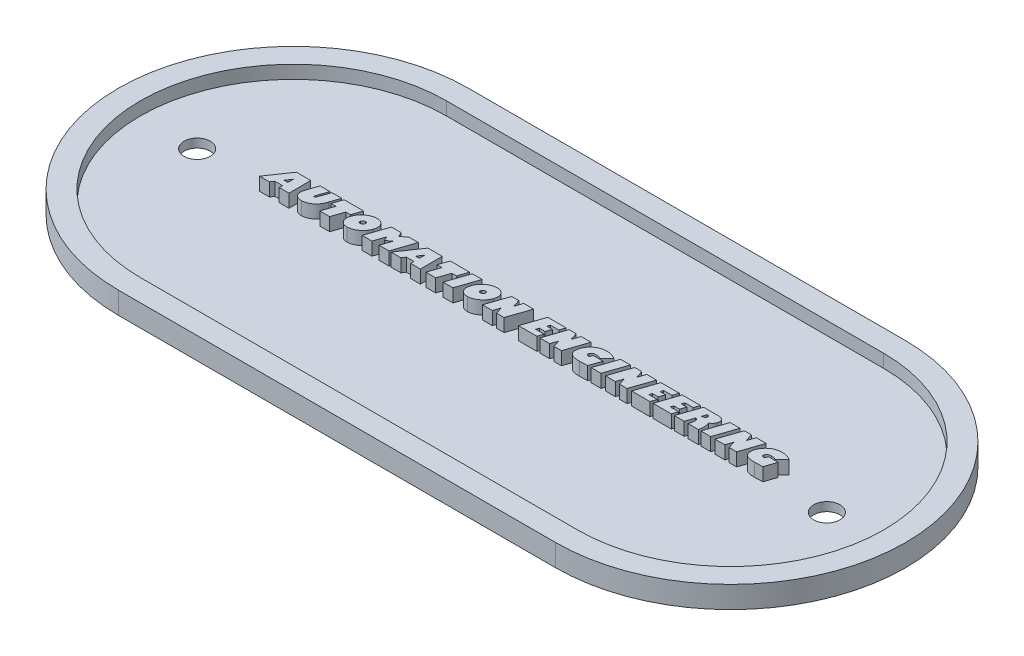
from build123d import *

# Parameters (mm, degrees)
BOSS_EXTRUDE1_DEPTH = 5
CUT_EXTRUDE1_DEPTH  = 3
BOSS_EXTRUDE2_DEPTH = 3
SKETCH4_R           = 3
CUT_EXTRUDE2_DEPTH  = 3


with BuildPart() as part:
    # Sketch1 → Boss-Extrude1 (new body)
    with BuildSketch(Plane(origin=(0, 0, 0), x_dir=(1, 0, 0), z_dir=(0, 1, 0))):
        with BuildLine():
            Line((0, 40), (100, 40))
            ThreePointArc((100, 40), (140, 0), (100, -40))
            Line((100, -40), (0, -40))
            ThreePointArc((0, -40), (-40, 0), (0, 40))
        make_face()
    extrude(amount=BOSS_EXTRUDE1_DEPTH)

    # Sketch2 → Cut-Extrude1 (cut)
    with BuildSketch(Plane(origin=(0, 5, 0), x_dir=(1, 0, 0), z_dir=(0, 1, 0))):
        with BuildLine():
            Line((100, 35), (0, 35))
            ThreePointArc((0, 35), (-35, 0), (0, -35))
            Line((0, -35), (100, -35))
            ThreePointArc((100, -35), (135, 0), (100, 35))
        make_face()
    extrude(amount=-CUT_EXTRUDE1_DEPTH, mode=Mode.SUBTRACT)

    # Sketch3 → Boss-Extrude2 (add)
    with BuildSketch(Plane(origin=(0, 2, 0), x_dir=(1, 0, 0), z_dir=(0, 1, 0))):
        Polygon((-4.188884775, -1.288840129), (-6.424236337, -1.288840129), (-3.008220712, 3.711159871), (0.265216788, 3.711159871), (0.288654288, -1.288840129), (-1.941814462, -1.288840129), (-1.92911915, -0.538840129), (-3.6908379, -0.538840129), align=None)
        Polygon((-2.821697275, 0.711159871), (-1.950603525, 0.711159871), (-1.957439462, 1.977761434), align=None, mode=Mode.SUBTRACT)
        with BuildLine():
            Line((7.350177725, 3.711159871), (6.5825996, 1.452370809))
            add(Edge.make_bspline(
                [(6.5825996, 1.452370809), (6.561528943, 1.391672481), (6.51993875, 1.271863444), (6.451088904, 1.096810885), (6.379022821, 0.927677441), (6.302731167, 0.765034597), (6.22419065, 0.608014453), (6.139413198, 0.458943169), (6.053201046, 0.314953178), (5.961679396, 0.178448604), (5.868605787, 0.046769398), (5.769267873, -0.076711984), (5.668200553, -0.195437621), (5.562169695, -0.306802321), (5.453113332, -0.412524789), (5.339333504, -0.511189098), (5.222532954, -0.603989697), (5.063174105, -0.717351463), (4.861401063, -0.845063964), (4.617489679, -0.980503928), (4.373406615, -1.094467347), (4.129495714, -1.187416274), (3.886308035, -1.261487565), (3.642971416, -1.313493016), (3.400138789, -1.344532245), (3.238284821, -1.34907902), (3.157794913, -1.351340129)],
                knots=[0, 0, 0, 0, 0.000192737, 0.000380433, 0.000564185, 0.000744182, 0.000919314, 0.001090714, 0.00125853, 0.001422665, 0.001583641, 0.001742103, 0.001897916, 0.00205127, 0.002203213, 0.002353416, 0.002502881, 0.002650575, 0.002939909, 0.003218776, 0.003487032, 0.003747293, 0.004001248, 0.004248904, 0.004492976, 0.004734426, 0.004734426, 0.004734426, 0.004734426], degree=3))
            add(Edge.make_bspline(
                [(3.157794913, -1.351340129), (3.100470526, -1.350126516), (2.987532139, -1.347735499), (2.821206213, -1.331477332), (2.66141658, -1.301644662), (2.507644689, -1.261677556), (2.359490277, -1.210998138), (2.217428305, -1.148184529), (2.081297703, -1.074036157), (1.9533166, -0.988182758), (1.834193504, -0.894750881), (1.728951938, -0.79141544), (1.637789293, -0.680655976), (1.559963329, -0.563097113), (1.496987468, -0.438225001), (1.449035389, -0.306027719), (1.41448879, -0.166633129), (1.395636398, -0.018879925), (1.389273303, 0.13788184), (1.394303174, 0.305630259), (1.412542864, 0.484918936), (1.442195983, 0.675862105), (1.483537547, 0.878159703), (1.536722396, 1.092072903), (1.600865349, 1.318023704), (1.651965434, 1.471120203), (1.678302725, 1.550027059)],
                knots=[0, 0, 0, 0, 0.000171975, 0.000338818, 0.000500672, 0.000659134, 0.000815094, 0.000969875, 0.001124582, 0.001279508, 0.001431717, 0.001578117, 0.001721036, 0.001861339, 0.00200022, 0.002139554, 0.002282376, 0.002430157, 0.002585581, 0.002752644, 0.002933189, 0.003125859, 0.003332127, 0.0035524, 0.003787013, 0.004036543, 0.004036543, 0.004036543, 0.004036543], degree=3))
            Line((1.678302725, 1.550027059), (2.412677725, 3.711159871))
            Line((2.412677725, 3.711159871), (4.662677725, 3.711159871))
            Line((4.662677725, 3.711159871), (3.878498038, 1.403542684))
            add(Edge.make_bspline(
                [(3.878498038, 1.403542684), (3.868716673, 1.373927013), (3.850153777, 1.317722928), (3.824105029, 1.238021314), (3.804728166, 1.166127365), (3.789319836, 1.103244779), (3.776840781, 1.049044283), (3.769844851, 1.003050708), (3.767147794, 0.965339942), (3.770791335, 0.927967408), (3.783336239, 0.891072187), (3.811518304, 0.858436501), (3.850952703, 0.838185602), (3.880834881, 0.836872517), (3.897052725, 0.836159871)],
                knots=[0, 0, 0, 0, 9.3572e-05, 0.000177579, 0.000251495, 0.000316866, 0.000371841, 0.000418246, 0.000456382, 0.000484853, 0.000530575, 0.000570721, 0.000611339, 0.000659548, 0.000659548, 0.000659548, 0.000659548], degree=3))
            add(Edge.make_bspline(
                [(3.897052725, 0.836159871), (3.92093615, 0.838096727), (3.969606578, 0.842043715), (4.036562184, 0.879977497), (4.097181554, 0.93703569), (4.138433596, 1.001842447), (4.171116763, 1.064180438), (4.198083722, 1.12025295), (4.226341622, 1.183780252), (4.255785125, 1.254838348), (4.286823132, 1.333259147), (4.318913157, 1.419703546), (4.353377858, 1.513241533), (4.375707893, 1.578623392), (4.3872871, 1.612527059)],
                knots=[0, 0, 0, 0, 7.1128e-05, 0.000144948, 0.000225097, 0.000319354, 0.000373525, 0.000436421, 0.000505928, 0.0005821, 0.000667151, 0.000758932, 0.000858718, 0.000966194, 0.000966194, 0.000966194, 0.000966194], degree=3))
            Line((4.3872871, 1.612527059), (5.100177725, 3.711159871))
            Line((5.100177725, 3.711159871), (7.350177725, 3.711159871))
        make_face()
        Polygon((7.148029288, 1.461159871), (7.912677725, 3.711159871), (12.350177725, 3.711159871), (11.585529288, 1.461159871), (10.523029288, 1.461159871), (9.588458975, -1.288840129), (7.338458975, -1.288840129), (8.273029288, 1.461159871), align=None)
        with BuildLine():
            add(Edge.make_bspline(
                [(13.627521475, -1.351340129), (13.583561474, -1.350796161), (13.497178768, -1.349727248), (13.370061346, -1.340762352), (13.24751814, -1.326131271), (13.12942109, -1.305935815), (13.015884943, -1.27897351), (12.906408034, -1.24882555), (12.802180551, -1.209593571), (12.701900593, -1.166603162), (12.606891004, -1.115895536), (12.515337937, -1.061392751), (12.428578039, -1.000261562), (12.347631328, -0.931600004), (12.268552167, -0.860356867), (12.197067883, -0.78018673), (12.127741694, -0.69634614), (12.065009853, -0.605837634), (12.007850315, -0.511302129), (11.955188469, -0.414358381), (11.911041513, -0.314131797), (11.872101974, -0.211665114), (11.841288813, -0.106445333), (11.816650147, 0.001162076), (11.799372931, 0.11148078), (11.787057102, 0.224220573), (11.783971005, 0.339726373), (11.785518224, 0.457403711), (11.794594015, 0.577691662), (11.810091757, 0.700604578), (11.833183498, 0.825887934), (11.860989714, 0.954214889), (11.897493007, 1.084636002), (11.925724318, 1.171866581), (11.940021475, 1.216042684)],
                knots=[0, 0, 0, 0, 0.000131868, 0.000259125, 0.000382072, 0.000502002, 0.000618311, 0.000732063, 0.000842363, 0.000952129, 0.001059151, 0.001165165, 0.001271651, 0.001377057, 0.001483479, 0.001590621, 0.00169891, 0.001809714, 0.001920587, 0.00203025, 0.002140411, 0.00224888, 0.002358881, 0.002469042, 0.00257982, 0.002693706, 0.002809007, 0.002926211, 0.003046649, 0.003170684, 0.003297686, 0.003428713, 0.003564469, 0.003703762, 0.003703762, 0.003703762, 0.003703762], degree=3))
            add(Edge.make_bspline(
                [(11.940021475, 1.216042684), (11.971985658, 1.304258434), (12.035715002, 1.480140664), (12.159168891, 1.732069312), (12.297987205, 1.975959106), (12.460684892, 2.207107088), (12.640632985, 2.430061961), (12.841440984, 2.641909651), (13.061779531, 2.84352157), (13.299578352, 3.031921176), (13.54701628, 3.205409179), (13.801004745, 3.356182338), (14.056617223, 3.485002992), (14.314294642, 3.590943377), (14.574981228, 3.672983786), (14.837852997, 3.729840741), (15.103024146, 3.767043349), (15.280719138, 3.771452009), (15.369708975, 3.773659871)],
                knots=[0, 0, 0, 0, 0.000281294, 0.000560837, 0.000840401, 0.001122413, 0.001407772, 0.001699295, 0.001997204, 0.002302995, 0.002608847, 0.00290311, 0.003188297, 0.003466848, 0.003738034, 0.004006974, 0.004272979, 0.004539838, 0.004539838, 0.004539838, 0.004539838], degree=3))
            add(Edge.make_bspline(
                [(15.369708975, 3.773659871), (15.413669609, 3.773113522), (15.500378341, 3.772035893), (15.628132506, 3.763031563), (15.751381162, 3.7486629), (15.869581057, 3.72781059), (15.983636095, 3.702916917), (16.092852199, 3.6706259), (16.197551722, 3.632056052), (16.298616716, 3.589726485), (16.394379939, 3.539645386), (16.485222335, 3.483455231), (16.572900297, 3.423355348), (16.654476411, 3.355587324), (16.732134157, 3.282913284), (16.805831307, 3.204807225), (16.873729993, 3.119765191), (16.936934697, 3.029860946), (16.995877113, 2.936959791), (17.046350284, 2.839471782), (17.091412339, 2.740196205), (17.129835694, 2.63814631), (17.160704685, 2.533234401), (17.186718259, 2.426181183), (17.20364598, 2.316023448), (17.215716524, 2.20394243), (17.220467709, 2.089126518), (17.218403626, 1.971755939), (17.209690353, 1.851758744), (17.193422991, 1.729356789), (17.172725142, 1.604259671), (17.142345679, 1.47722246), (17.107804747, 1.346973578), (17.079446051, 1.260186635), (17.065021475, 1.216042684)],
                knots=[0, 0, 0, 0, 0.000131868, 0.0002601, 0.000384015, 0.000503946, 0.000620038, 0.000734062, 0.000845278, 0.000954658, 0.001062545, 0.001169066, 0.001274991, 0.001381149, 0.001486857, 0.001593945, 0.001702993, 0.001812998, 0.001923553, 0.002032757, 0.002142028, 0.002250497, 0.002359562, 0.002469943, 0.002580722, 0.002693636, 0.002807998, 0.002925202, 0.003045641, 0.003168707, 0.00329554, 0.003425829, 0.003560386, 0.003699679, 0.003699679, 0.003699679, 0.003699679], degree=3))
            add(Edge.make_bspline(
                [(17.065021475, 1.216042684), (17.032630371, 1.127549038), (16.96809265, 0.951229694), (16.845235331, 0.697700717), (16.704721643, 0.453880407), (16.543698257, 0.220390278), (16.362309808, -0.002461392), (16.161736292, -0.215711568), (15.941212331, -0.418519028), (15.702944607, -0.60744186), (15.454827623, -0.781025454), (15.200913058, -0.93302984), (14.945202745, -1.062883668), (14.685886749, -1.167504316), (14.424969262, -1.250682962), (14.161002673, -1.30757896), (13.895180389, -1.34472064), (13.716836852, -1.349131265), (13.627521475, -1.351340129)],
                knots=[0, 0, 0, 0, 0.000282556, 0.000562979, 0.000843878, 0.001126136, 0.001412869, 0.001705102, 0.002003672, 0.002310835, 0.002616687, 0.002911451, 0.003197948, 0.003476131, 0.003749473, 0.004018413, 0.004285386, 0.004553221, 0.004553221, 0.004553221, 0.004553221], degree=3))
        make_face()
        with BuildLine():
            add(Edge.make_bspline(
                [(14.71150585, 1.836159871), (14.676189649, 1.834465178), (14.605543719, 1.831075142), (14.501346221, 1.803457787), (14.400786652, 1.75763273), (14.305681986, 1.695347215), (14.217974186, 1.621389385), (14.144331495, 1.53545469), (14.083828594, 1.440734529), (14.057043783, 1.371215826), (14.0435371, 1.336159871)],
                knots=[0, 0, 0, 0, 0.000105834, 0.000211709, 0.00032098, 0.000436102, 0.00055177, 0.000663943, 0.000774498, 0.000886955, 0.000886955, 0.000886955, 0.000886955], degree=3))
            add(Edge.make_bspline(
                [(14.0435371, 1.336159871), (14.033416355, 1.301951851), (14.01439594, 1.237663029), (14.007373001, 1.1412063), (14.023193221, 1.053519495), (14.059257316, 0.976062661), (14.115577298, 0.9130412), (14.187828074, 0.867172941), (14.27545321, 0.840264738), (14.338259639, 0.837585027), (14.3716621, 0.836159871)],
                knots=[0, 0, 0, 0, 0.000106821, 0.000200754, 0.00028714, 0.000371447, 0.000453763, 0.0005372, 0.000625226, 0.000725223, 0.000725223, 0.000725223, 0.000725223], degree=3))
            add(Edge.make_bspline(
                [(14.3716621, 0.836159871), (14.407622887, 0.837845869), (14.479224196, 0.841202848), (14.584528146, 0.868592362), (14.684957772, 0.914912651), (14.781050636, 0.975771676), (14.867835643, 1.050998061), (14.941676502, 1.137090313), (15.003400896, 1.231293615), (15.030103323, 1.301060641), (15.0435371, 1.336159871)],
                knots=[0, 0, 0, 0, 0.000107781, 0.000214602, 0.000323872, 0.000438467, 0.000554773, 0.000666946, 0.000778021, 0.000890478, 0.000890478, 0.000890478, 0.000890478], degree=3))
            add(Edge.make_bspline(
                [(15.0435371, 1.336159871), (15.053799453, 1.370363934), (15.073080634, 1.434627434), (15.07834329, 1.531113454), (15.06325572, 1.618627187), (15.026207804, 1.695509823), (14.970922983, 1.759283517), (14.897966979, 1.805339297), (14.809326311, 1.832109566), (14.745558356, 1.83474991), (14.71150585, 1.836159871)],
                knots=[0, 0, 0, 0, 0.000106821, 0.000200698, 0.000287084, 0.00037051, 0.000453558, 0.000536995, 0.000625954, 0.000727896, 0.000727896, 0.000727896, 0.000727896], degree=3))
        make_face(mode=Mode.SUBTRACT)
        Polygon((17.025958975, -1.288840129), (18.725177725, 3.711159871), (20.908771475, 3.711159871), (21.431232413, 2.663308309), (22.669513663, 3.711159871), (24.850177725, 3.711159871), (23.150958975, -1.288840129), (20.900958975, -1.288840129), (21.7466621, 1.198464559), (20.603107413, 0.225808309), (20.1216621, 1.198464559), (19.275958975, -1.288840129), align=None)
        Polygon((25.873615225, -1.288840129), (23.638263663, -1.288840129), (27.054279288, 3.711159871), (30.327716788, 3.711159871), (30.351154288, -1.288840129), (28.120685538, -1.288840129), (28.13338085, -0.538840129), (26.3716621, -0.538840129), align=None)
        Polygon((27.240802725, 0.711159871), (28.111896475, 0.711159871), (28.105060538, 1.977761434), align=None, mode=Mode.SUBTRACT)
        Polygon((31.398029288, 1.461159871), (32.162677725, 3.711159871), (36.600177725, 3.711159871), (35.835529288, 1.461159871), (34.773029288, 1.461159871), (33.838458975, -1.288840129), (31.588458975, -1.288840129), (32.523029288, 1.461159871), align=None)
        Polygon((35.525958975, -1.288840129), (37.225177725, 3.711159871), (39.475177725, 3.711159871), (37.775958975, -1.288840129), align=None)
        with BuildLine():
            add(Edge.make_bspline(
                [(41.127521475, -1.351340129), (41.083561474, -1.350796161), (40.997178768, -1.349727248), (40.870061346, -1.340762352), (40.74751814, -1.326131271), (40.62942109, -1.305935815), (40.515884943, -1.27897351), (40.406408034, -1.24882555), (40.302180551, -1.209593571), (40.201900593, -1.166603162), (40.106891004, -1.115895536), (40.015337937, -1.061392751), (39.928578039, -1.000261562), (39.847631328, -0.931600004), (39.768552167, -0.860356867), (39.697067883, -0.78018673), (39.627741694, -0.69634614), (39.565009853, -0.605837634), (39.507850315, -0.511302129), (39.455188469, -0.414358381), (39.411041513, -0.314131797), (39.372101974, -0.211665114), (39.341288813, -0.106445333), (39.316650147, 0.001162076), (39.299372931, 0.11148078), (39.287057102, 0.224220573), (39.283971005, 0.339726373), (39.285518224, 0.457403711), (39.294594015, 0.577691662), (39.310091757, 0.700604578), (39.333183498, 0.825887934), (39.360989714, 0.954214889), (39.397493007, 1.084636002), (39.425724318, 1.171866581), (39.440021475, 1.216042684)],
                knots=[0, 0, 0, 0, 0.000131868, 0.000259125, 0.000382072, 0.000502002, 0.000618311, 0.000732063, 0.000842363, 0.000952129, 0.001059151, 0.001165165, 0.001271651, 0.001377057, 0.001483479, 0.001590621, 0.00169891, 0.001809714, 0.001920587, 0.00203025, 0.002140411, 0.00224888, 0.002358881, 0.002469042, 0.00257982, 0.002693706, 0.002809007, 0.002926211, 0.003046649, 0.003170684, 0.003297686, 0.003428713, 0.003564469, 0.003703762, 0.003703762, 0.003703762, 0.003703762], degree=3))
            add(Edge.make_bspline(
                [(39.440021475, 1.216042684), (39.471985658, 1.304258434), (39.535715002, 1.480140664), (39.659168891, 1.732069312), (39.797987205, 1.975959106), (39.960684892, 2.207107088), (40.140632985, 2.430061961), (40.341440984, 2.641909651), (40.561779531, 2.84352157), (40.799578352, 3.031921176), (41.04701628, 3.205409179), (41.301004745, 3.356182338), (41.556617223, 3.485002992), (41.814294642, 3.590943377), (42.074981228, 3.672983786), (42.337852997, 3.729840741), (42.603024146, 3.767043349), (42.780719138, 3.771452009), (42.869708975, 3.773659871)],
                knots=[0, 0, 0, 0, 0.000281294, 0.000560837, 0.000840401, 0.001122413, 0.001407772, 0.001699295, 0.001997204, 0.002302995, 0.002608847, 0.00290311, 0.003188297, 0.003466848, 0.003738034, 0.004006974, 0.004272979, 0.004539838, 0.004539838, 0.004539838, 0.004539838], degree=3))
            add(Edge.make_bspline(
                [(42.869708975, 3.773659871), (42.913669609, 3.773113522), (43.000378341, 3.772035893), (43.128132506, 3.763031563), (43.251381162, 3.7486629), (43.369581057, 3.72781059), (43.483636095, 3.702916917), (43.592852199, 3.6706259), (43.697551722, 3.632056052), (43.798616716, 3.589726485), (43.894379939, 3.539645386), (43.985222335, 3.483455231), (44.072900297, 3.423355348), (44.154476411, 3.355587324), (44.232134157, 3.282913284), (44.305831307, 3.204807225), (44.373729993, 3.119765191), (44.436934697, 3.029860946), (44.495877113, 2.936959791), (44.546350284, 2.839471782), (44.591412339, 2.740196205), (44.629835694, 2.63814631), (44.660704685, 2.533234401), (44.686718259, 2.426181183), (44.70364598, 2.316023448), (44.715716524, 2.20394243), (44.720467709, 2.089126518), (44.718403626, 1.971755939), (44.709690353, 1.851758744), (44.693422991, 1.729356789), (44.672725142, 1.604259671), (44.642345679, 1.47722246), (44.607804747, 1.346973578), (44.579446051, 1.260186635), (44.565021475, 1.216042684)],
                knots=[0, 0, 0, 0, 0.000131868, 0.0002601, 0.000384015, 0.000503946, 0.000620038, 0.000734062, 0.000845278, 0.000954658, 0.001062545, 0.001169066, 0.001274991, 0.001381149, 0.001486857, 0.001593945, 0.001702993, 0.001812998, 0.001923553, 0.002032757, 0.002142028, 0.002250497, 0.002359562, 0.002469943, 0.002580722, 0.002693636, 0.002807998, 0.002925202, 0.003045641, 0.003168707, 0.00329554, 0.003425829, 0.003560386, 0.003699679, 0.003699679, 0.003699679, 0.003699679], degree=3))
            add(Edge.make_bspline(
                [(44.565021475, 1.216042684), (44.532630371, 1.127549038), (44.46809265, 0.951229694), (44.345235331, 0.697700717), (44.204721643, 0.453880407), (44.043698257, 0.220390278), (43.862309808, -0.002461392), (43.661736292, -0.215711568), (43.441212331, -0.418519028), (43.202944607, -0.60744186), (42.954827623, -0.781025454), (42.700913058, -0.93302984), (42.445202745, -1.062883668), (42.185886749, -1.167504316), (41.924969262, -1.250682962), (41.661002673, -1.30757896), (41.395180389, -1.34472064), (41.216836852, -1.349131265), (41.127521475, -1.351340129)],
                knots=[0, 0, 0, 0, 0.000282556, 0.000562979, 0.000843878, 0.001126136, 0.001412869, 0.001705102, 0.002003672, 0.002310835, 0.002616687, 0.002911451, 0.003197948, 0.003476131, 0.003749473, 0.004018413, 0.004285386, 0.004553221, 0.004553221, 0.004553221, 0.004553221], degree=3))
        make_face()
        with BuildLine():
            add(Edge.make_bspline(
                [(42.21150585, 1.836159871), (42.176189649, 1.834465178), (42.105543719, 1.831075142), (42.001346221, 1.803457787), (41.900786652, 1.75763273), (41.805681986, 1.695347215), (41.717974186, 1.621389385), (41.644331495, 1.53545469), (41.583828594, 1.440734529), (41.557043783, 1.371215826), (41.5435371, 1.336159871)],
                knots=[0, 0, 0, 0, 0.000105834, 0.000211709, 0.00032098, 0.000436102, 0.00055177, 0.000663943, 0.000774498, 0.000886955, 0.000886955, 0.000886955, 0.000886955], degree=3))
            add(Edge.make_bspline(
                [(41.5435371, 1.336159871), (41.533416355, 1.301951851), (41.51439594, 1.237663029), (41.507373001, 1.1412063), (41.523193221, 1.053519495), (41.559257316, 0.976062661), (41.615577298, 0.9130412), (41.687828074, 0.867172941), (41.77545321, 0.840264738), (41.838259639, 0.837585027), (41.8716621, 0.836159871)],
                knots=[0, 0, 0, 0, 0.000106821, 0.000200754, 0.00028714, 0.000371447, 0.000453763, 0.0005372, 0.000625226, 0.000725223, 0.000725223, 0.000725223, 0.000725223], degree=3))
            add(Edge.make_bspline(
                [(41.8716621, 0.836159871), (41.907622887, 0.837845869), (41.979224196, 0.841202848), (42.084528146, 0.868592362), (42.184957772, 0.914912651), (42.281050636, 0.975771676), (42.367835643, 1.050998061), (42.441676502, 1.137090313), (42.503400896, 1.231293615), (42.530103323, 1.301060641), (42.5435371, 1.336159871)],
                knots=[0, 0, 0, 0, 0.000107781, 0.000214602, 0.000323872, 0.000438467, 0.000554773, 0.000666946, 0.000778021, 0.000890478, 0.000890478, 0.000890478, 0.000890478], degree=3))
            add(Edge.make_bspline(
                [(42.5435371, 1.336159871), (42.553799453, 1.370363934), (42.573080634, 1.434627434), (42.57834329, 1.531113454), (42.56325572, 1.618627187), (42.526207804, 1.695509823), (42.470922983, 1.759283517), (42.397966979, 1.805339297), (42.309326311, 1.832109566), (42.245558356, 1.83474991), (42.21150585, 1.836159871)],
                knots=[0, 0, 0, 0, 0.000106821, 0.000200698, 0.000287084, 0.00037051, 0.000453558, 0.000536995, 0.000625954, 0.000727896, 0.000727896, 0.000727896, 0.000727896], degree=3))
        make_face(mode=Mode.SUBTRACT)
        Polygon((49.5122871, -1.327902629), (47.808185538, -1.327902629), (47.3013496, 0.257058309), (46.775958975, -1.288840129), (44.525958975, -1.288840129), (46.225177725, 3.711159871), (47.835529288, 3.711159871), (48.397052725, 2.010964559), (48.975177725, 3.711159871), (51.225177725, 3.711159871), align=None)
        Polygon((57.388263663, -0.038840129), (56.963458975, -1.288840129), (52.775958975, -1.288840129), (54.475177725, 3.711159871), (58.662677725, 3.711159871), (58.237873038, 2.461159871), (56.331623038, 2.461159871), (56.119708975, 1.836159871), (57.400958975, 1.836159871), (56.976154288, 0.586159871), (55.663654288, 0.586159871), (55.450763663, -0.038840129), align=None)
        Polygon((62.6372871, -1.327902629), (60.933185538, -1.327902629), (60.4263496, 0.257058309), (59.900958975, -1.288840129), (57.650958975, -1.288840129), (59.350177725, 3.711159871), (60.960529288, 3.711159871), (61.522052725, 2.010964559), (62.100177725, 3.711159871), (64.350177725, 3.711159871), align=None)
        with BuildLine():
            Line((70.19588085, 3.081277059), (68.607013663, 1.523659871))
            add(Edge.make_bspline(
                [(68.607013663, 1.523659871), (68.558768212, 1.548600632), (68.463771603, 1.597709671), (68.318401461, 1.661477226), (68.172938437, 1.715215122), (68.027184635, 1.759331591), (67.88139754, 1.793687303), (67.735588525, 1.818055305), (67.589762448, 1.833326946), (67.492466667, 1.835216974), (67.443927725, 1.836159871)],
                knots=[0, 0, 0, 0, 0.000162902, 0.000320758, 0.000475862, 0.000627861, 0.00077733, 0.000924871, 0.001071115, 0.001216704, 0.001216704, 0.001216704, 0.001216704], degree=3))
            add(Edge.make_bspline(
                [(67.443927725, 1.836159871), (67.381271739, 1.834278731), (67.258614756, 1.830596163), (67.080899729, 1.796450239), (66.914463757, 1.741596048), (66.786142868, 1.67735265), (66.692386589, 1.615727418), (66.627269712, 1.567381106), (66.569777954, 1.513719148), (66.516438936, 1.458568587), (66.470205671, 1.398653695), (66.43137348, 1.33430283), (66.39651637, 1.26751725), (66.379291492, 1.220168156), (66.370685538, 1.196511434)],
                knots=[0, 0, 0, 0, 0.000187807, 0.000367657, 0.000540594, 0.00071223, 0.000796197, 0.000877058, 0.000955164, 0.001031842, 0.001107043, 0.001181576, 0.001257132, 0.001332574, 0.001332574, 0.001332574, 0.001332574], degree=3))
            add(Edge.make_bspline(
                [(66.370685538, 1.196511434), (66.363723965, 1.174499612), (66.350463534, 1.132571404), (66.33839501, 1.070024358), (66.334303413, 1.011973886), (66.337666311, 0.957462828), (66.350765483, 0.907845143), (66.370046005, 0.861827991), (66.398654812, 0.821047612), (66.433747205, 0.783632265), (66.47751682, 0.751234031), (66.529108824, 0.724043147), (66.588110698, 0.700773485), (66.654719203, 0.68116814), (66.72935199, 0.667042899), (66.811526416, 0.656495496), (66.901487045, 0.649388529), (66.964095504, 0.6489092), (66.9966621, 0.648659871)],
                knots=[0, 0, 0, 0, 6.9219e-05, 0.000131848, 0.000190572, 0.000243451, 0.000294848, 0.000343833, 0.000392318, 0.000443436, 0.000497147, 0.000554822, 0.000617929, 0.000687148, 0.000762799, 0.00084553, 0.000935634, 0.00103331, 0.00103331, 0.00103331, 0.00103331], degree=3))
            Line((66.9966621, 0.648659871), (67.2310371, 1.336159871))
            Line((67.2310371, 1.336159871), (69.4810371, 1.336159871))
            Line((69.4810371, 1.336159871), (68.592365225, -1.278097941))
            add(Edge.make_bspline(
                [(68.592365225, -1.278097941), (68.482020774, -1.284098324), (68.270795419, -1.295584475), (67.968023567, -1.309821627), (67.693644615, -1.323027586), (67.447197522, -1.332518182), (67.228776223, -1.340505604), (67.038343139, -1.34623131), (66.876241531, -1.350829812), (66.777589037, -1.351181251), (66.732990225, -1.351340129)],
                knots=[0, 0, 0, 0, 0.000331521, 0.00063461, 0.000909317, 0.001155605, 0.001374494, 0.001565014, 0.00172717, 0.001860963, 0.001860963, 0.001860963, 0.001860963], degree=3))
            add(Edge.make_bspline(
                [(66.732990225, -1.351340129), (66.657787161, -1.350782457), (66.510908269, -1.34969327), (66.295925087, -1.341077441), (66.091705937, -1.325525392), (65.898339042, -1.303670473), (65.715205888, -1.278573704), (65.543765491, -1.243683643), (65.38293883, -1.205042851), (65.233012923, -1.160481271), (65.09417482, -1.108597031), (64.965770118, -1.051191726), (64.848247512, -0.987575792), (64.740875403, -0.918790141), (64.646241451, -0.841530909), (64.560031572, -0.76100611), (64.486525882, -0.672354609), (64.404108932, -0.547226924), (64.320147166, -0.382005116), (64.243630163, -0.174740259), (64.190927718, 0.040446326), (64.166429439, 0.263851809), (64.165316922, 0.494684598), (64.190887013, 0.733418144), (64.240341355, 0.9804865), (64.292271774, 1.144532811), (64.318927725, 1.228737996)],
                knots=[0, 0, 0, 0, 0.000225605, 0.000440628, 0.000645327, 0.000839876, 0.001024387, 0.001199628, 0.001364479, 0.0015205, 0.001668516, 0.001808822, 0.001942097, 0.002069133, 0.002190686, 0.002308109, 0.002422517, 0.002535191, 0.002757066, 0.002976749, 0.00319679, 0.003419919, 0.003649414, 0.003887971, 0.004139054, 0.004403861, 0.004403861, 0.004403861, 0.004403861], degree=3))
            add(Edge.make_bspline(
                [(64.318927725, 1.228737996), (64.339727531, 1.287594194), (64.381326012, 1.405303386), (64.456121758, 1.577319214), (64.540586254, 1.745464268), (64.632851289, 1.910426028), (64.735220128, 2.071012174), (64.845673912, 2.228647021), (64.965461038, 2.382899478), (65.09533872, 2.531779461), (65.232519512, 2.674867423), (65.376340734, 2.811035663), (65.526653973, 2.939199977), (65.684072338, 3.0581453), (65.847456904, 3.169074739), (66.017774153, 3.270303287), (66.193950658, 3.364405095), (66.375965986, 3.45024878), (66.563778938, 3.526420376), (66.755712562, 3.592845723), (66.951768108, 3.648397612), (67.151118691, 3.694678624), (67.354655351, 3.729545225), (67.561601365, 3.754708138), (67.772435946, 3.771200526), (67.914274317, 3.772834511), (67.985919913, 3.773659871)],
                knots=[0, 0, 0, 0, 0.000187225, 0.00037444, 0.000562235, 0.000751562, 0.000941206, 0.001133294, 0.001328833, 0.001526808, 0.001725725, 0.001923295, 0.002120737, 0.002318005, 0.002514918, 0.002712878, 0.002912097, 0.003113925, 0.003316306, 0.003519828, 0.003722917, 0.003927355, 0.0041335, 0.004342083, 0.004552624, 0.004767523, 0.004767523, 0.004767523, 0.004767523], degree=3))
            add(Edge.make_bspline(
                [(67.985919913, 3.773659871), (68.086908724, 3.77119939), (68.288768755, 3.766281293), (68.590363337, 3.732888979), (68.888993105, 3.674145287), (69.182605219, 3.596116328), (69.465408928, 3.498066161), (69.729359014, 3.378397696), (69.974432502, 3.242451883), (70.122663697, 3.134566062), (70.19588085, 3.081277059)],
                knots=[0, 0, 0, 0, 0.000302961, 0.000605569, 0.000908943, 0.001215232, 0.001516363, 0.001805703, 0.002083815, 0.002355266, 0.002355266, 0.002355266, 0.002355266], degree=3))
        make_face()
        Polygon((69.400958975, -1.288840129), (71.100177725, 3.711159871), (73.350177725, 3.711159871), (71.650958975, -1.288840129), align=None)
        Polygon((77.6372871, -1.327902629), (75.933185538, -1.327902629), (75.4263496, 0.257058309), (74.900958975, -1.288840129), (72.650958975, -1.288840129), (74.350177725, 3.711159871), (75.960529288, 3.711159871), (76.522052725, 2.010964559), (77.100177725, 3.711159871), (79.350177725, 3.711159871), align=None)
        Polygon((83.263263663, -0.038840129), (82.838458975, -1.288840129), (78.650958975, -1.288840129), (80.350177725, 3.711159871), (84.537677725, 3.711159871), (84.112873038, 2.461159871), (82.206623038, 2.461159871), (81.994708975, 1.836159871), (83.275958975, 1.836159871), (82.851154288, 0.586159871), (81.538654288, 0.586159871), (81.325763663, -0.038840129), align=None)
        Polygon((88.138263663, -0.038840129), (87.713458975, -1.288840129), (83.525958975, -1.288840129), (85.225177725, 3.711159871), (89.412677725, 3.711159871), (88.987873038, 2.461159871), (87.081623038, 2.461159871), (86.869708975, 1.836159871), (88.150958975, 1.836159871), (87.726154288, 0.586159871), (86.413654288, 0.586159871), (86.200763663, -0.038840129), align=None)
        with BuildLine():
            Line((90.100177725, 3.711159871), (93.392169913, 3.711159871))
            add(Edge.make_bspline(
                [(93.392169913, 3.711159871), (93.460902178, 3.709866687), (93.593129039, 3.707378865), (93.783912321, 3.687924929), (93.958800216, 3.655212174), (94.117996567, 3.609687573), (94.261285993, 3.551193156), (94.388652099, 3.478657297), (94.500121881, 3.392099665), (94.595010917, 3.29303643), (94.673703344, 3.184751849), (94.733415203, 3.068102759), (94.777341006, 2.945796677), (94.802610024, 2.816455264), (94.810178569, 2.680476394), (94.799658409, 2.537940561), (94.772441879, 2.388818977), (94.741258255, 2.289644928), (94.725177725, 2.238503621)],
                knots=[0, 0, 0, 0, 0.000206168, 0.000396625, 0.000574555, 0.000739282, 0.000892528, 0.00103776, 0.001177627, 0.00131438, 0.001447998, 0.00157772, 0.001706211, 0.001836636, 0.001971628, 0.002113566, 0.002264501, 0.002425204, 0.002425204, 0.002425204, 0.002425204], degree=3))
            add(Edge.make_bspline(
                [(94.725177725, 2.238503621), (94.704229436, 2.181678839), (94.66251584, 2.068525636), (94.579145767, 1.908623458), (94.483458751, 1.757129375), (94.372134595, 1.615516495), (94.24578672, 1.483905859), (94.10531156, 1.360894611), (93.949551574, 1.248494103), (93.837700722, 1.182306218), (93.780841788, 1.148659871)],
                knots=[0, 0, 0, 0, 0.000181528, 0.00036147, 0.000539729, 0.000718483, 0.000900831, 0.001086311, 0.001277941, 0.001476078, 0.001476078, 0.001476078, 0.001476078], degree=3))
            add(Edge.make_bspline(
                [(93.780841788, 1.148659871), (93.799820347, 1.10881136), (93.837958354, 1.02873453), (93.887702697, 0.904557708), (93.930608923, 0.775972475), (93.967973699, 0.643114717), (93.997950315, 0.505786615), (94.021381686, 0.363966013), (94.03893862, 0.218337821), (94.049767006, 0.067774555), (94.053196367, -0.086676597), (94.05146193, -0.245977798), (94.042665395, -0.409212175), (94.026497728, -0.576872402), (94.005356905, -0.748928536), (93.976522528, -0.925311973), (93.942900768, -1.106236739), (93.915069023, -1.227408741), (93.900958975, -1.288840129)],
                knots=[0, 0, 0, 0, 0.000132388, 0.000266038, 0.000400991, 0.000538891, 0.000679875, 0.000822439, 0.000969975, 0.001119774, 0.001275097, 0.001433312, 0.00159761, 0.001765331, 0.001938544, 0.002117556, 0.002301425, 0.002490498, 0.002490498, 0.002490498, 0.002490498], degree=3))
            Line((93.900958975, -1.288840129), (91.588458975, -1.288840129))
            add(Edge.make_bspline(
                [(91.588458975, -1.288840129), (91.610379742, -1.209204), (91.652647036, -1.055650809), (91.706673291, -0.831958035), (91.748857047, -0.624238843), (91.784747074, -0.43347981), (91.806730676, -0.258315745), (91.820464739, -0.099312714), (91.822463754, 0.043602757), (91.815868669, 0.170890727), (91.796865402, 0.282875177), (91.766133704, 0.381060304), (91.721088948, 0.464075761), (91.663254616, 0.532816084), (91.592172477, 0.585342113), (91.508872283, 0.623418369), (91.412691174, 0.644118242), (91.344738345, 0.647099207), (91.3091621, 0.648659871)],
                knots=[0, 0, 0, 0, 0.000247787, 0.00047778, 0.000690179, 0.000883652, 0.001059894, 0.001219579, 0.00136217, 0.001488389, 0.001601417, 0.001702093, 0.001795619, 0.0018829, 0.001969424, 0.00205857, 0.002155702, 0.002262434, 0.002262434, 0.002262434, 0.002262434], degree=3))
            Line((91.3091621, 0.648659871), (90.650958975, -1.288840129))
            Line((90.650958975, -1.288840129), (88.400958975, -1.288840129))
            Line((88.400958975, -1.288840129), (90.100177725, 3.711159871))
        make_face()
        with BuildLine():
            Line((91.9888496, 2.648659871), (91.670490225, 1.711159871))
            Line((91.670490225, 1.711159871), (91.729083975, 1.711159871))
            add(Edge.make_bspline(
                [(91.729083975, 1.711159871), (91.774094202, 1.712304372), (91.86076889, 1.714508299), (91.984447397, 1.735899088), (92.095431102, 1.772045038), (92.193463042, 1.822277228), (92.279748584, 1.886186238), (92.350028375, 1.967523634), (92.410273935, 2.060760458), (92.437037055, 2.131125068), (92.450763663, 2.167214559)],
                knots=[0, 0, 0, 0, 0.000134939, 0.000259847, 0.000375036, 0.00048379, 0.000589064, 0.000694899, 0.000804626, 0.000920162, 0.000920162, 0.000920162, 0.000920162], degree=3))
            add(Edge.make_bspline(
                [(92.450763663, 2.167214559), (92.460002462, 2.197893973), (92.477645325, 2.256480882), (92.485737609, 2.345015588), (92.477246781, 2.427837235), (92.455990141, 2.49175261), (92.430562274, 2.537962541), (92.404196003, 2.568079966), (92.371696046, 2.593428601), (92.332762851, 2.61431582), (92.287377519, 2.62928195), (92.236127456, 2.641256219), (92.178473131, 2.647843469), (92.137953536, 2.64837967), (92.116779288, 2.648659871)],
                knots=[0, 0, 0, 0, 9.5932e-05, 0.000183197, 0.000264726, 0.000344093, 0.000383459, 0.000422228, 0.000463255, 0.000506511, 0.000554073, 0.000606189, 0.00066421, 0.000727717, 0.000727717, 0.000727717, 0.000727717], degree=3))
            Line((92.116779288, 2.648659871), (91.9888496, 2.648659871))
        make_face(mode=Mode.SUBTRACT)
        Polygon((94.463458975, -1.288840129), (96.162677725, 3.711159871), (98.412677725, 3.711159871), (96.713458975, -1.288840129), align=None)
        Polygon((102.6997871, -1.327902629), (100.995685538, -1.327902629), (100.4888496, 0.257058309), (99.963458975, -1.288840129), (97.713458975, -1.288840129), (99.412677725, 3.711159871), (101.023029288, 3.711159871), (101.584552725, 2.010964559), (102.162677725, 3.711159871), (104.412677725, 3.711159871), align=None)
        with BuildLine():
            Line((110.25838085, 3.081277059), (108.669513663, 1.523659871))
            add(Edge.make_bspline(
                [(108.669513663, 1.523659871), (108.621268212, 1.548600632), (108.526271603, 1.597709671), (108.380901461, 1.661477226), (108.235438437, 1.715215122), (108.089684635, 1.759331591), (107.94389754, 1.793687303), (107.798088525, 1.818055305), (107.652262448, 1.833326946), (107.554966667, 1.835216974), (107.506427725, 1.836159871)],
                knots=[0, 0, 0, 0, 0.000162902, 0.000320758, 0.000475862, 0.000627861, 0.00077733, 0.000924871, 0.001071115, 0.001216704, 0.001216704, 0.001216704, 0.001216704], degree=3))
            add(Edge.make_bspline(
                [(107.506427725, 1.836159871), (107.443771739, 1.834278731), (107.321114756, 1.830596163), (107.143399729, 1.796450239), (106.976963757, 1.741596048), (106.848642868, 1.67735265), (106.754886589, 1.615727418), (106.689769712, 1.567381106), (106.632277954, 1.513719148), (106.578938936, 1.458568587), (106.532705671, 1.398653695), (106.49387348, 1.33430283), (106.45901637, 1.26751725), (106.441791492, 1.220168156), (106.433185538, 1.196511434)],
                knots=[0, 0, 0, 0, 0.000187807, 0.000367657, 0.000540594, 0.00071223, 0.000796197, 0.000877058, 0.000955164, 0.001031842, 0.001107043, 0.001181576, 0.001257132, 0.001332574, 0.001332574, 0.001332574, 0.001332574], degree=3))
            add(Edge.make_bspline(
                [(106.433185538, 1.196511434), (106.426223965, 1.174499612), (106.412963534, 1.132571404), (106.40089501, 1.070024358), (106.396803413, 1.011973886), (106.400166311, 0.957462828), (106.413265483, 0.907845143), (106.432546005, 0.861827991), (106.461154812, 0.821047612), (106.496247205, 0.783632265), (106.54001682, 0.751234031), (106.591608824, 0.724043147), (106.650610698, 0.700773485), (106.717219203, 0.68116814), (106.79185199, 0.667042899), (106.874026416, 0.656495496), (106.963987045, 0.649388529), (107.026595504, 0.6489092), (107.0591621, 0.648659871)],
                knots=[0, 0, 0, 0, 6.9219e-05, 0.000131848, 0.000190572, 0.000243451, 0.000294848, 0.000343833, 0.000392318, 0.000443436, 0.000497147, 0.000554822, 0.000617929, 0.000687148, 0.000762799, 0.00084553, 0.000935634, 0.00103331, 0.00103331, 0.00103331, 0.00103331], degree=3))
            Line((107.0591621, 0.648659871), (107.2935371, 1.336159871))
            Line((107.2935371, 1.336159871), (109.5435371, 1.336159871))
            Line((109.5435371, 1.336159871), (108.654865225, -1.278097941))
            add(Edge.make_bspline(
                [(108.654865225, -1.278097941), (108.544520774, -1.284098324), (108.333295419, -1.295584475), (108.030523567, -1.309821627), (107.756144615, -1.323027586), (107.509697522, -1.332518182), (107.291276223, -1.340505604), (107.100843139, -1.34623131), (106.938741531, -1.350829812), (106.840089037, -1.351181251), (106.795490225, -1.351340129)],
                knots=[0, 0, 0, 0, 0.000331521, 0.00063461, 0.000909317, 0.001155605, 0.001374494, 0.001565014, 0.00172717, 0.001860963, 0.001860963, 0.001860963, 0.001860963], degree=3))
            add(Edge.make_bspline(
                [(106.795490225, -1.351340129), (106.720287161, -1.350782457), (106.573408269, -1.34969327), (106.358425087, -1.341077441), (106.154205937, -1.325525392), (105.960839042, -1.303670473), (105.777705888, -1.278573704), (105.606265491, -1.243683643), (105.44543883, -1.205042851), (105.295512923, -1.160481271), (105.15667482, -1.108597031), (105.028270118, -1.051191726), (104.910747512, -0.987575792), (104.803375403, -0.918790141), (104.708741451, -0.841530909), (104.622531572, -0.76100611), (104.549025882, -0.672354609), (104.466608932, -0.547226924), (104.382647166, -0.382005116), (104.306130163, -0.174740259), (104.253427718, 0.040446326), (104.228929439, 0.263851809), (104.227816922, 0.494684598), (104.253387013, 0.733418144), (104.302841355, 0.9804865), (104.354771774, 1.144532811), (104.381427725, 1.228737996)],
                knots=[0, 0, 0, 0, 0.000225605, 0.000440628, 0.000645327, 0.000839876, 0.001024387, 0.001199628, 0.001364479, 0.0015205, 0.001668516, 0.001808822, 0.001942097, 0.002069133, 0.002190686, 0.002308109, 0.002422517, 0.002535191, 0.002757066, 0.002976749, 0.00319679, 0.003419919, 0.003649414, 0.003887971, 0.004139054, 0.004403861, 0.004403861, 0.004403861, 0.004403861], degree=3))
            add(Edge.make_bspline(
                [(104.381427725, 1.228737996), (104.402227531, 1.287594194), (104.443826012, 1.405303386), (104.518621758, 1.577319214), (104.603086254, 1.745464268), (104.695351289, 1.910426028), (104.797720128, 2.071012174), (104.908173912, 2.228647021), (105.027961038, 2.382899478), (105.15783872, 2.531779461), (105.295019512, 2.674867423), (105.438840734, 2.811035663), (105.589153973, 2.939199977), (105.746572338, 3.0581453), (105.909956904, 3.169074739), (106.080274153, 3.270303287), (106.256450658, 3.364405095), (106.438465986, 3.45024878), (106.626278938, 3.526420376), (106.818212562, 3.592845723), (107.014268108, 3.648397612), (107.213618691, 3.694678624), (107.417155351, 3.729545225), (107.624101365, 3.754708138), (107.834935946, 3.771200526), (107.976774317, 3.772834511), (108.048419913, 3.773659871)],
                knots=[0, 0, 0, 0, 0.000187225, 0.00037444, 0.000562235, 0.000751562, 0.000941206, 0.001133294, 0.001328833, 0.001526808, 0.001725725, 0.001923295, 0.002120737, 0.002318005, 0.002514918, 0.002712878, 0.002912097, 0.003113925, 0.003316306, 0.003519828, 0.003722917, 0.003927355, 0.0041335, 0.004342083, 0.004552624, 0.004767523, 0.004767523, 0.004767523, 0.004767523], degree=3))
            add(Edge.make_bspline(
                [(108.048419913, 3.773659871), (108.149408724, 3.77119939), (108.351268755, 3.766281293), (108.652863337, 3.732888979), (108.951493105, 3.674145287), (109.245105219, 3.596116328), (109.527908928, 3.498066161), (109.791859014, 3.378397696), (110.036932502, 3.242451883), (110.185163697, 3.134566062), (110.25838085, 3.081277059)],
                knots=[0, 0, 0, 0, 0.000302961, 0.000605569, 0.000908943, 0.001215232, 0.001516363, 0.001805703, 0.002083815, 0.002355266, 0.002355266, 0.002355266, 0.002355266], degree=3))
        make_face()
    extrude(amount=BOSS_EXTRUDE2_DEPTH)

    # Sketch4 → Cut-Extrude2 (cut, through all)
    with BuildSketch(Plane(origin=(0, 2, 0), x_dir=(1, 0, 0), z_dir=(0, 1, 0))):
        with Locations((-22, 0)):
            Circle(SKETCH4_R)
        with Locations((122, 0)):
            Circle(SKETCH4_R)
    extrude(amount=-CUT_EXTRUDE2_DEPTH, mode=Mode.SUBTRACT)


solid = part.part
